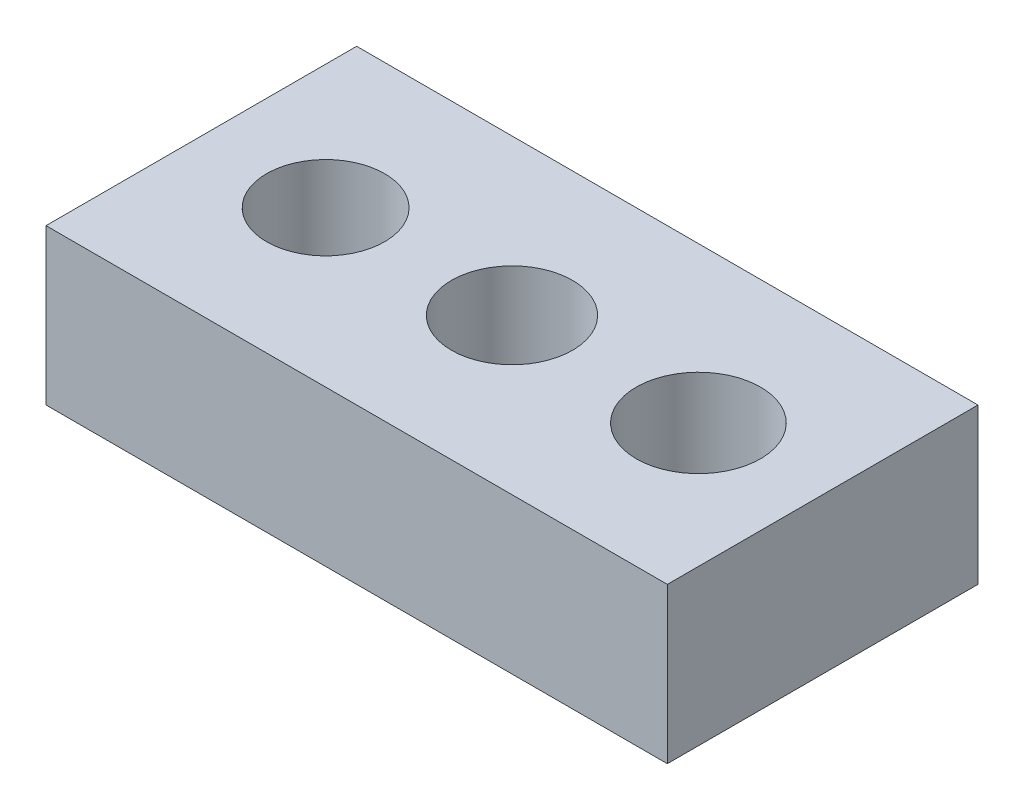
from build123d import *

# Parameters (mm, degrees)
SKETCH1_W                   = 20
SKETCH1_H                   = 10
BOSS_EXTRUDE1_DEPTH         = 5
TAP_DRILL_FOR_M4X0_7_TAP1_D = 3.8
TAP_DRILL_FOR_M4X0_7_TAP2_D = 3.9
TAP_DRILL_FOR_M4X0_7_TAP3_D = 4


with BuildPart() as part:
    # Sketch1 → Boss-Extrude1 (new body)
    with BuildSketch(Plane(origin=(0, 0, 0), x_dir=(1, 0, 0), z_dir=(0, 1, 0))):
        with Locations((10, 5)):
            Rectangle(SKETCH1_W, SKETCH1_H)
    extrude(amount=BOSS_EXTRUDE1_DEPTH)

    # Tap Drill for M4x0.7 Tap1 (through all)
    with Locations(Plane(origin=(4, 5, -5), x_dir=(0, 0, 1), z_dir=(0, 1, 0))):
        with Locations((0, 0)):
            Hole(TAP_DRILL_FOR_M4X0_7_TAP1_D / 2)

    # Tap Drill for M4x0.7 Tap2 (through all)
    with Locations(Plane(origin=(10, 5, -5), x_dir=(0, 0, 1), z_dir=(0, 1, 0))):
        with Locations((0, 0)):
            Hole(TAP_DRILL_FOR_M4X0_7_TAP2_D / 2)

    # Tap Drill for M4x0.7 Tap3 (through all)
    with Locations(Plane(origin=(16, 5, -5), x_dir=(0, 0, 1), z_dir=(0, 1, 0))):
        with Locations((0, 0)):
            Hole(TAP_DRILL_FOR_M4X0_7_TAP3_D / 2)


solid = part.part
